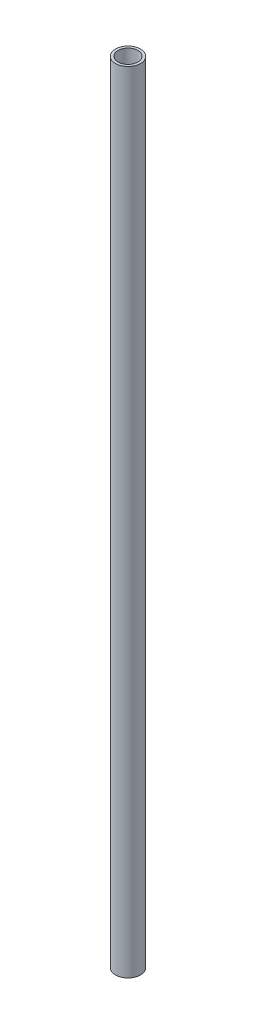
from build123d import *

# Parameters (mm, degrees)
SKETCH1_R           = 7.9375
SKETCH1_R_2         = 6.35
BOSS_EXTRUDE1_DEPTH = 500


with BuildPart() as part:
    # Sketch1 → Boss-Extrude1 (new body)
    with BuildSketch(Plane(origin=(0, 0, 0), x_dir=(1, 0, 0), z_dir=(0, 1, 0))):
        Circle(SKETCH1_R)
        Circle(SKETCH1_R_2, mode=Mode.SUBTRACT)
    extrude(amount=BOSS_EXTRUDE1_DEPTH)


solid = part.part
